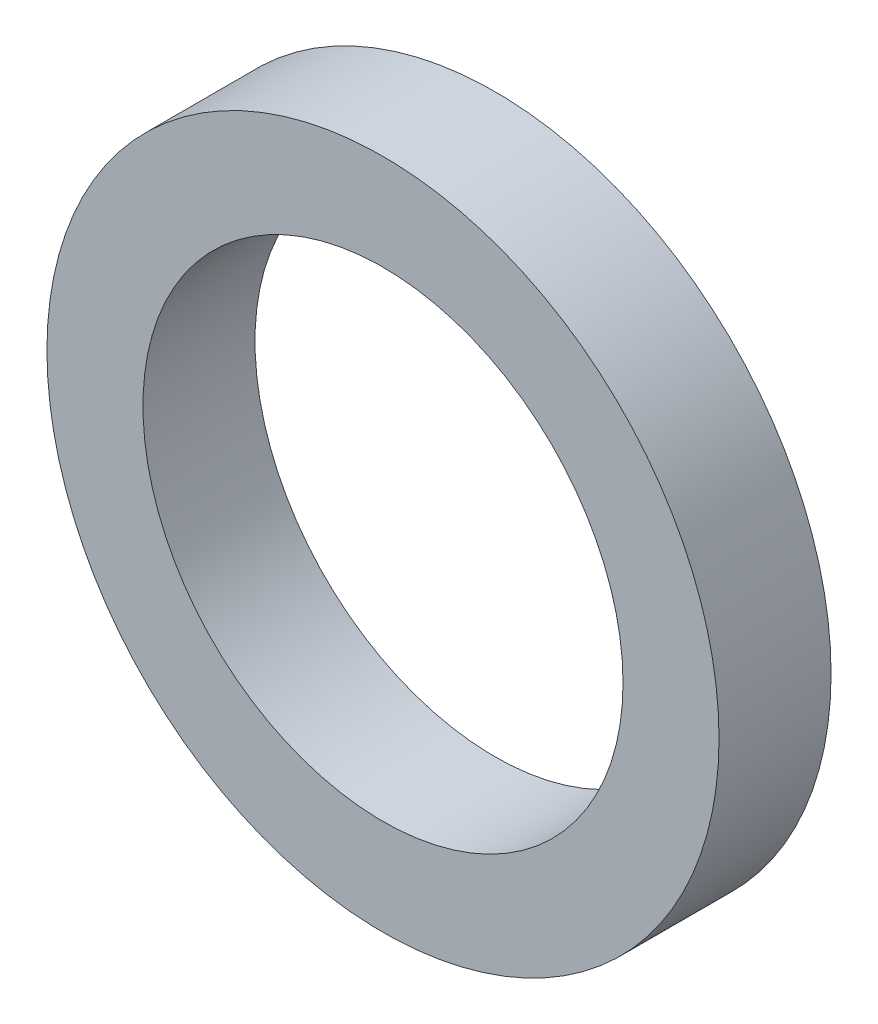
from build123d import *

# Parameters (mm, degrees)
SKETCH1_R      = 21
SKETCH1_R_2    = 15
EXTRUDE1_DEPTH = 7


with BuildPart() as part:
    # Sketch1 → Extrude1 (new body)
    with BuildSketch(Plane.XY):
        Circle(SKETCH1_R)
        Circle(SKETCH1_R_2, mode=Mode.SUBTRACT)
    extrude(amount=EXTRUDE1_DEPTH)


solid = part.part
